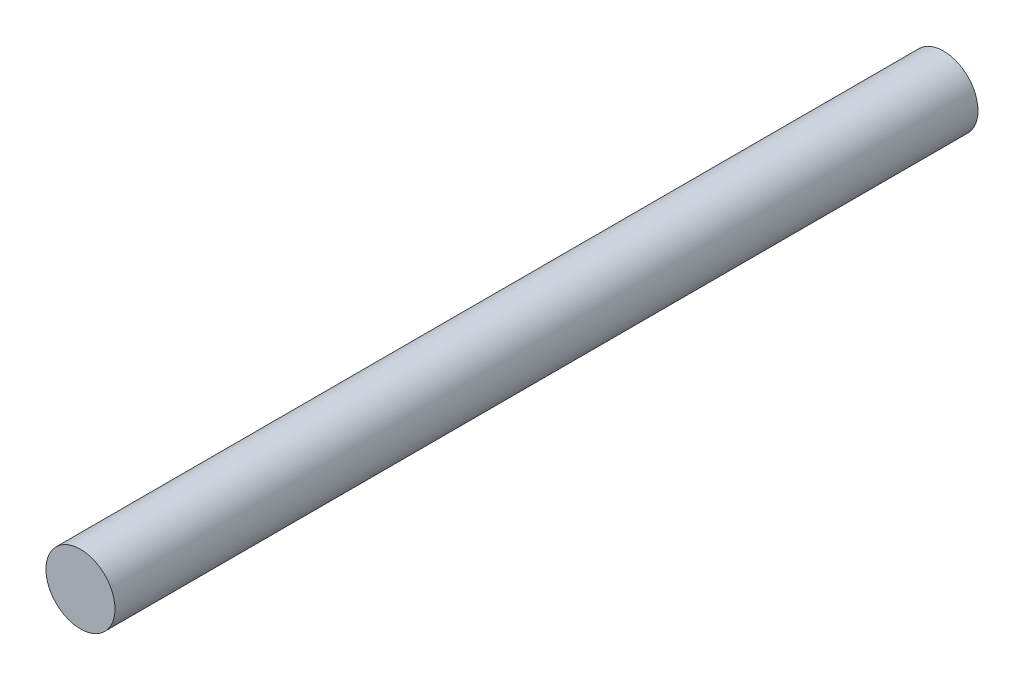
from build123d import *

# Parameters (mm, degrees)
SKIZZE1_R                       = 10
AUFSATZ_LINEAR_AUSTRAGEN1_DEPTH = 250


with BuildPart() as part:
    # Skizze1 → Aufsatz-Linear austragen1 (new body)
    with BuildSketch(Plane.XY):
        Circle(SKIZZE1_R)
    extrude(amount=AUFSATZ_LINEAR_AUSTRAGEN1_DEPTH)


solid = part.part
